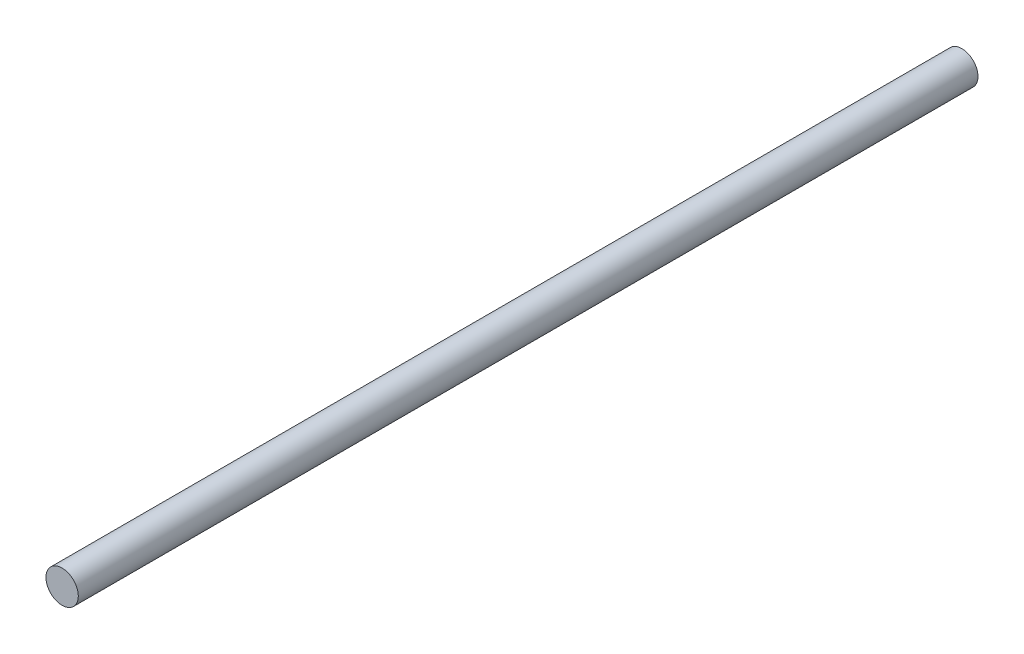
from build123d import *

# Parameters (mm, degrees)
ESBO_O1_R                = 6
RESSALTO_EXTRUS_O1_DEPTH = 334


with BuildPart() as part:
    # Esboço1 → Ressalto-extrusão1 (new body)
    with BuildSketch(Plane.XY):
        Circle(ESBO_O1_R)
    extrude(amount=RESSALTO_EXTRUS_O1_DEPTH)


solid = part.part
